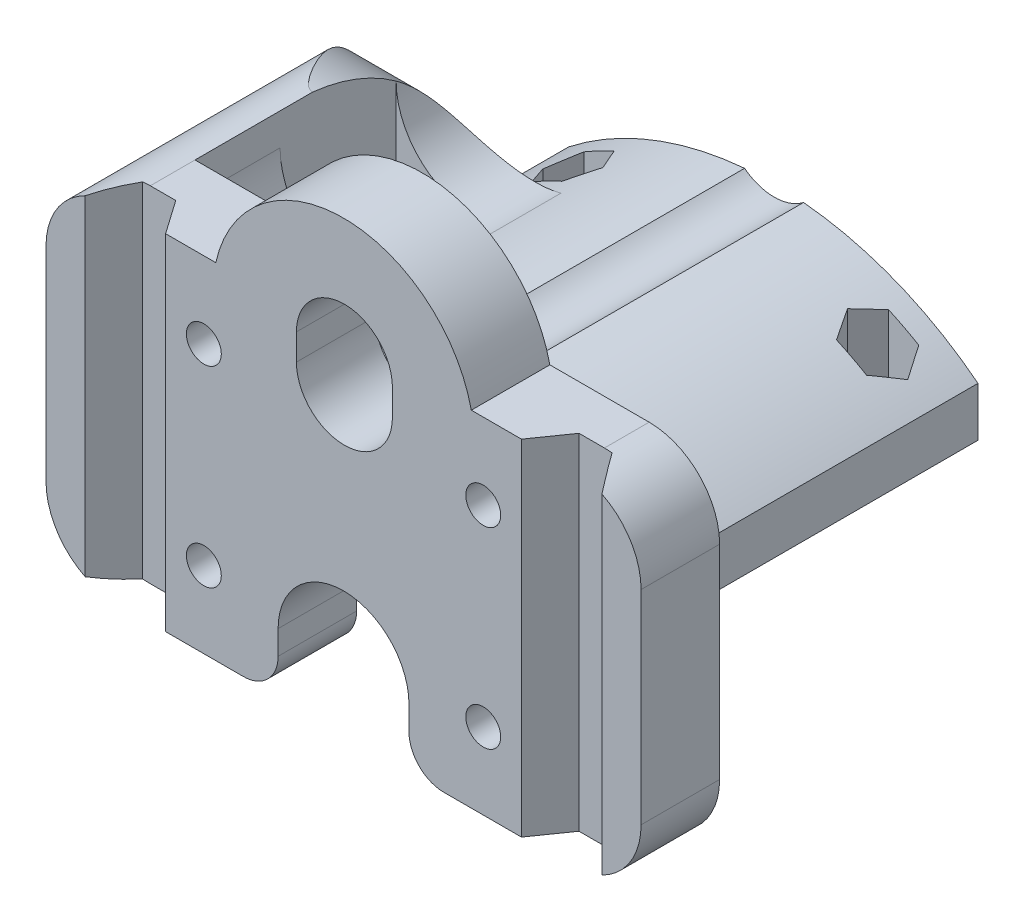
from build123d import *

# Parameters (mm, degrees)
SKETCH1_R           = 2
BOSS_EXTRUDE1_DEPTH = 49.25
SKETCH2_R           = 2
CUT_EXTRUDE1_DEPTH  = 40.25
CUT_EXTRUDE2_DEPTH  = 50.25
BOSS_EXTRUDE2_DEPTH = 30.5
CUT_EXTRUDE3_REACH  = 70.2
BOSS_EXTRUDE3_DEPTH = 19.5
CUT_EXTRUDE4_DEPTH  = 19.5
CUT_EXTRUDE5_DEPTH  = 40.5
SKETCH9_R           = 4.05
CUT_EXTRUDE6_DEPTH  = 2.4
CUT_EXTRUDE7_REACH  = 41.5
CUT_EXTRUDE8_REACH  = 70.2
SKETCH11_R          = 4.5
CUT_EXTRUDE9_REACH  = 36.95
SKETCH12_R          = 1.8
CUT_EXTRUDE10_REACH = 34.6


with BuildPart() as part:
    # Sketch1 → Boss-Extrude1 (new body)
    with BuildSketch(Plane.XY):
        with BuildLine():
            Line((14.643684646, 19.75), (26.025, 19.75))
            ThreePointArc((26.025, 19.75), (31.734887258, 17.384887258), (34.1, 11.675))
            Line((34.1, 11.675), (34.1, -11.675))
            ThreePointArc((34.1, -11.675), (31.734887258, -17.384887258), (26.025, -19.75))
            Line((26.025, -19.75), (11.5, -19.75))
            ThreePointArc((11.5, -19.75), (8.671572875, -18.578427125), (7.5, -15.75))
            Line((7.5, -15.75), (7.5, -13))
            ThreePointArc((7.5, -13), (0, -5.5), (-7.5, -13))
            Line((-7.5, -13), (-7.5, -15.75))
            ThreePointArc((-7.5, -15.75), (-8.671572875, -18.578427125), (-11.5, -19.75))
            Line((-11.5, -19.75), (-26.025, -19.75))
            ThreePointArc((-26.025, -19.75), (-31.734887258, -17.384887258), (-34.1, -11.675))
            Line((-34.1, -11.675), (-34.1, 11.675))
            ThreePointArc((-34.1, 11.675), (-31.734887258, 17.384887258), (-26.025, 19.75))
            Line((-26.025, 19.75), (-14.643684646, 19.75))
            ThreePointArc((-14.643684646, 19.75), (0, 31.5), (14.643684646, 19.75))
        make_face()
        with Locations((-16.01, -11)):
            Circle(SKETCH1_R, mode=Mode.SUBTRACT)
        with Locations((16.01, -11)):
            Circle(SKETCH1_R, mode=Mode.SUBTRACT)
        with Locations((-16.01, 11)):
            Circle(SKETCH1_R, mode=Mode.SUBTRACT)
        with Locations((16.01, 11)):
            Circle(SKETCH1_R, mode=Mode.SUBTRACT)
    extrude(amount=-BOSS_EXTRUDE1_DEPTH)

    # Sketch2 → Cut-Extrude1 (cut)
    with BuildSketch(Plane(origin=(0, 0, -49.25), x_dir=(-1, 0, 0), z_dir=(0, 0, -1))):
        with BuildLine():
            Line((11.5, -19.75), (26.025, -19.75))
            ThreePointArc((26.025, -19.75), (31.734887258, -17.384887258), (34.1, -11.675))
            Line((34.1, -11.675), (34.1, 11.675))
            ThreePointArc((34.1, 11.675), (31.734887258, 17.384887258), (26.025, 19.75))
            Line((26.025, 19.75), (14.643684646, 19.75))
            ThreePointArc((14.643684646, 19.75), (0, 31.5), (-14.643684646, 19.75))
            Line((-14.643684646, 19.75), (-26.025, 19.75))
            ThreePointArc((-26.025, 19.75), (-31.734887258, 17.384887258), (-34.1, 11.675))
            Line((-34.1, 11.675), (-34.1, -11.675))
            ThreePointArc((-34.1, -11.675), (-31.734887258, -17.384887258), (-26.025, -19.75))
            Line((-26.025, -19.75), (-11.5, -19.75))
            ThreePointArc((-11.5, -19.75), (-8.671572875, -18.578427125), (-7.5, -15.75))
            Line((-7.5, -15.75), (-7.5, -13))
            ThreePointArc((-7.5, -13), (0, -5.5), (7.5, -13))
            Line((7.5, -13), (7.5, -15.75))
            ThreePointArc((7.5, -15.75), (8.671572875, -18.578427125), (11.5, -19.75))
        make_face()
        with Locations((-16.01, -11)):
            Circle(SKETCH2_R, mode=Mode.SUBTRACT)
        with Locations((16.01, -11)):
            Circle(SKETCH2_R, mode=Mode.SUBTRACT)
        with BuildLine():
            Line((23.4625, -3.45), (-23.4625, -3.45))
            Line((-23.4625, -3.45), (-23.4625, 2.2))
            ThreePointArc((-23.4625, 2.2), (0, 10.309700625), (23.4625, 2.2))
            Line((23.4625, 2.2), (23.4625, -3.45))
        make_face(mode=Mode.SUBTRACT)
        with Locations((-16.01, 11)):
            Circle(SKETCH2_R, mode=Mode.SUBTRACT)
        with Locations((16.01, 11)):
            Circle(SKETCH2_R, mode=Mode.SUBTRACT)
    extrude(amount=-CUT_EXTRUDE1_DEPTH, mode=Mode.SUBTRACT)

    # Sketch3 → Cut-Extrude2 (cut, through all)
    with BuildSketch(Plane(origin=(0, 0, -49.25), x_dir=(-1, 0, 0), z_dir=(0, 0, -1))):
        with BuildLine():
            Line((5.400029356, 17.5), (5.400029356, 14.500008735))
            ThreePointArc((5.400029356, 14.500008735), (-0.099987836, 8.999989471), (-5.600009173, 14.500004591))
            Line((-5.600009173, 14.500004591), (-5.600029356, 17.499962997))
            ThreePointArc((-5.600029356, 17.499962997), (-0.100018502, 23.000029356), (5.400029356, 17.5))
        make_face()
    extrude(amount=-CUT_EXTRUDE2_DEPTH, mode=Mode.SUBTRACT)

    # Sketch4 → Boss-Extrude2 (add)
    with BuildSketch(Plane(origin=(0, 0, -9), x_dir=(-1, 0, 0), z_dir=(0, 0, -1))):
        with BuildLine():
            ThreePointArc((34.1, 11.675), (31.734887258, 17.384887258), (26.025, 19.75))
            Line((26.025, 19.75), (26.025, 16.08))
            ThreePointArc((26.025, 16.08), (22.115315274, 8.671322277), (13.792758824, 7.717805418))
            ThreePointArc((13.792758824, 7.717805418), (18.830829022, 5.315002189), (23.4625, 2.2))
            Line((23.4625, 2.2), (23.4625, -3.45))
            Line((23.4625, -3.45), (26.6625, -3.45))
            Line((26.6625, -3.45), (26.6625, -19.724796193))
            ThreePointArc((26.6625, -19.724796193), (31.955996438, -17.154863707), (34.1, -11.675))
            Line((34.1, -11.675), (34.1, 11.675))
        make_face()
    extrude(amount=BOSS_EXTRUDE2_DEPTH)

    # Sketch5 → Cut-Extrude3 (cut, up to next)
    with BuildSketch(Plane.ZY.offset(34.1), mode=Mode.PRIVATE) as cut_extrude3_sk1:
        with BuildLine():
            ThreePointArc((-36.446473341, 11.675), (-30.322556644, 17.17937534), (-22.5, 19.75))
            Line((-22.5, 19.75), (-39.5, 19.75))
            Line((-39.5, 19.75), (-39.5, 11.675))
            Line((-39.5, 11.675), (-36.446473341, 11.675))
        make_face()
    cut_extrude3_tool1 = extrude(cut_extrude3_sk1.sketch, amount=-CUT_EXTRUDE3_REACH, mode=Mode.PRIVATE) & part.part
    add(cut_extrude3_tool1.solids().sort_by_distance((-34.1, 16.750328, -34.812411))[0], mode=Mode.SUBTRACT)
    # Sketch5 → Cut-Extrude3 (cut, up to next)
    with BuildSketch(Plane.ZY.offset(34.1), mode=Mode.PRIVATE) as cut_extrude3_sk2:
        with BuildLine():
            ThreePointArc((-39.5, 5.475203807), (-38.243056783, 8.707993837), (-36.446473341, 11.675))
            Line((-36.446473341, 11.675), (-39.5, 11.675))
            Line((-39.5, 11.675), (-39.5, 5.475203807))
        make_face()
    cut_extrude3_tool2 = extrude(cut_extrude3_sk2.sketch, amount=-CUT_EXTRUDE3_REACH, mode=Mode.PRIVATE) & part.part
    add(cut_extrude3_tool2.solids().sort_by_distance((-34.1, 9.776794, -38.55104))[0], mode=Mode.SUBTRACT)

    # Sketch6 → Boss-Extrude3 (add)
    with BuildSketch(Plane(origin=(0, 0, -49.25), x_dir=(-1, 0, 0), z_dir=(0, 0, -1))):
        with BuildLine():
            Line((-23.4625, 2.2), (-23.4625, -3.45))
            Line((-23.4625, -3.45), (23.4625, -3.45))
            Line((23.4625, -3.45), (23.4625, 2.2))
            ThreePointArc((23.4625, 2.2), (13.955756335, 7.653869971), (3.287761431, 10.167186009))
            ThreePointArc((3.287761431, 10.167186009), (-0.086953501, 9.00000492), (-3.467163514, 10.151175119))
            ThreePointArc((-3.467163514, 10.151175119), (-14.039479716, 7.620692104), (-23.4625, 2.2))
        make_face()
    extrude(amount=-BOSS_EXTRUDE3_DEPTH)

    # Sketch7 → Cut-Extrude4 (cut)
    with BuildSketch(Plane.ZY.offset(34.1)):
        with BuildLine():
            Line((-39.5, -5.75), (-39.5, -19.724796193))
            Line((-39.5, -19.724796193), (-23.95, -19.724796193))
            ThreePointArc((-23.95, -19.724796193), (-33.696416785, -14.931028013), (-39.5, -5.75))
        make_face()
    extrude(amount=-CUT_EXTRUDE4_DEPTH, mode=Mode.SUBTRACT)

    # Sketch8 → Cut-Extrude5 (cut)
    with BuildSketch(Plane(origin=(0, 19.75, 0), x_dir=(1, 0, 0), z_dir=(0, 1, 0))):
        Polygon((-17.075, 32.05), (-26.025, 32.05), (-26.025, 18.75), (-18.960500232, 18.75), (-17.075, 20.635500232), align=None)
    extrude(amount=-CUT_EXTRUDE5_DEPTH, mode=Mode.SUBTRACT)

    # Sketch9 → Cut-Extrude6 (cut)
    with BuildSketch(Plane(origin=(0, 0, -9), x_dir=(-1, 0, 0), z_dir=(0, 0, -1))):
        with Locations((-16.01, 11)):
            Circle(SKETCH9_R)
        with Locations((16.01, 11)):
            Circle(SKETCH9_R)
        with Locations((-16.01, -11)):
            Circle(SKETCH9_R)
        with Locations((16.01, -11)):
            Circle(SKETCH9_R)
    extrude(amount=-CUT_EXTRUDE6_DEPTH, mode=Mode.SUBTRACT)

    # Sketch10 → Cut-Extrude7 (cut, up to next)
    with BuildSketch(Plane(origin=(0, 19.75, 0), x_dir=(1, 0, 0), z_dir=(0, 1, 0)), mode=Mode.PRIVATE) as cut_extrude7_sk1:
        Polygon((20.391684646, 0), (23.107093003, 3.878005034), (26.897093003, 3.878005034), (29.612501361, 0), align=None)
    cut_extrude7_tool1 = extrude(cut_extrude7_sk1.sketch, amount=-CUT_EXTRUDE7_REACH, mode=Mode.PRIVATE) & part.part
    add(cut_extrude7_tool1.solids().sort_by_distance((25.002093, 19.75, -1.669218))[0], mode=Mode.SUBTRACT)
    # Sketch10 → Cut-Extrude7 (cut, up to next)
    with BuildSketch(Plane(origin=(0, 19.75, 0), x_dir=(1, 0, 0), z_dir=(0, 1, 0)), mode=Mode.PRIVATE) as cut_extrude7_sk2:
        Polygon((-20.391584646, 0), (-23.106993003, 3.878005034), (-26.896993003, 3.878005034), (-29.612401361, 0), align=None)
    cut_extrude7_tool2 = extrude(cut_extrude7_sk2.sketch, amount=-CUT_EXTRUDE7_REACH, mode=Mode.PRIVATE) & part.part
    add(cut_extrude7_tool2.solids().sort_by_distance((-25.001993, 19.75, -1.669218))[0], mode=Mode.SUBTRACT)

    # Sketch11 → Cut-Extrude8 (cut, up to next)
    with BuildSketch(Plane.ZY.offset(34.1), mode=Mode.PRIVATE) as cut_extrude8_sk1:
        with Locations((-25, 3.9)):
            Circle(SKETCH11_R)
    cut_extrude8_tool1 = extrude(cut_extrude8_sk1.sketch, amount=-CUT_EXTRUDE8_REACH, mode=Mode.PRIVATE) & part.part
    add(cut_extrude8_tool1.solids().sort_by_distance((-34.1, 3.9, -25))[0], mode=Mode.SUBTRACT)

    # Sketch12 → Cut-Extrude9 (cut, up to next)
    with BuildSketch(Plane.XZ.offset(3.45), mode=Mode.PRIVATE) as cut_extrude9_sk1:
        with Locations((-17.4625, -15)):
            Circle(SKETCH12_R)
    cut_extrude9_tool1 = extrude(cut_extrude9_sk1.sketch, amount=-CUT_EXTRUDE9_REACH, mode=Mode.PRIVATE) & part.part
    add(cut_extrude9_tool1.solids().sort_by_distance((-17.4625, -3.45, -15))[0], mode=Mode.SUBTRACT)
    # Sketch12 → Cut-Extrude9 (cut, up to next)
    with BuildSketch(Plane.XZ.offset(3.45), mode=Mode.PRIVATE) as cut_extrude9_sk2:
        with Locations((-17.4625, -43.75)):
            Circle(SKETCH12_R)
    cut_extrude9_tool2 = extrude(cut_extrude9_sk2.sketch, amount=-CUT_EXTRUDE9_REACH, mode=Mode.PRIVATE) & part.part
    add(cut_extrude9_tool2.solids().sort_by_distance((-17.4625, -3.45, -43.75))[0], mode=Mode.SUBTRACT)
    # Sketch12 → Cut-Extrude9 (cut, up to next)
    with BuildSketch(Plane.XZ.offset(3.45), mode=Mode.PRIVATE) as cut_extrude9_sk3:
        with Locations((17.4625, -15)):
            Circle(SKETCH12_R)
    cut_extrude9_tool3 = extrude(cut_extrude9_sk3.sketch, amount=-CUT_EXTRUDE9_REACH, mode=Mode.PRIVATE) & part.part
    add(cut_extrude9_tool3.solids().sort_by_distance((17.4625, -3.45, -15))[0], mode=Mode.SUBTRACT)
    # Sketch12 → Cut-Extrude9 (cut, up to next)
    with BuildSketch(Plane.XZ.offset(3.45), mode=Mode.PRIVATE) as cut_extrude9_sk4:
        with Locations((17.4625, -43.75)):
            Circle(SKETCH12_R)
    cut_extrude9_tool4 = extrude(cut_extrude9_sk4.sketch, amount=-CUT_EXTRUDE9_REACH, mode=Mode.PRIVATE) & part.part
    add(cut_extrude9_tool4.solids().sort_by_distance((17.4625, -3.45, -43.75))[0], mode=Mode.SUBTRACT)

    # Sketch13 → Cut-Extrude10 (cut, up to next)
    with BuildSketch(Plane(origin=(0, -1.1004, 0), x_dir=(-1, 0, 0), z_dir=(0, -1, 0)), mode=Mode.PRIVATE) as cut_extrude10_sk1:
        Polygon((-15.737425, 46.737917547), (-19.187575, 46.737917547), (-20.91265, 43.75), (-19.187575, 40.762082453), (-15.737425, 40.762082453), (-14.01235, 43.75), align=None)
    cut_extrude10_tool1 = extrude(cut_extrude10_sk1.sketch, amount=-CUT_EXTRUDE10_REACH, mode=Mode.PRIVATE) & part.part
    add(cut_extrude10_tool1.solids().sort_by_distance((17.4625, -1.1004, -43.75))[0], mode=Mode.SUBTRACT)
    # Sketch13 → Cut-Extrude10 (cut, up to next)
    with BuildSketch(Plane(origin=(0, -1.1004, 0), x_dir=(-1, 0, 0), z_dir=(0, -1, 0)), mode=Mode.PRIVATE) as cut_extrude10_sk2:
        Polygon((-15.737425, 17.987917547), (-19.187575, 17.987917547), (-20.91265, 15), (-19.187575, 12.012082453), (-15.737425, 12.012082453), (-14.01235, 15), align=None)
    cut_extrude10_tool2 = extrude(cut_extrude10_sk2.sketch, amount=-CUT_EXTRUDE10_REACH, mode=Mode.PRIVATE) & part.part
    add(cut_extrude10_tool2.solids().sort_by_distance((17.4625, -1.1004, -15))[0], mode=Mode.SUBTRACT)
    # Sketch13 → Cut-Extrude10 (cut, up to next)
    with BuildSketch(Plane(origin=(0, -1.1004, 0), x_dir=(-1, 0, 0), z_dir=(0, -1, 0)), mode=Mode.PRIVATE) as cut_extrude10_sk3:
        Polygon((19.187575, 17.987917547), (15.737425, 17.987917547), (14.01235, 15), (15.737425, 12.012082453), (19.187575, 12.012082453), (20.91265, 15), align=None)
    cut_extrude10_tool3 = extrude(cut_extrude10_sk3.sketch, amount=-CUT_EXTRUDE10_REACH, mode=Mode.PRIVATE) & part.part
    add(cut_extrude10_tool3.solids().sort_by_distance((-17.4625, -1.1004, -15))[0], mode=Mode.SUBTRACT)
    # Sketch13 → Cut-Extrude10 (cut, up to next)
    with BuildSketch(Plane(origin=(0, -1.1004, 0), x_dir=(-1, 0, 0), z_dir=(0, -1, 0)), mode=Mode.PRIVATE) as cut_extrude10_sk4:
        Polygon((15.737425, 40.762082453), (19.187575, 40.762082453), (20.91265, 43.75), (19.187575, 46.737917547), (15.737425, 46.737917547), (14.01235, 43.75), align=None)
    cut_extrude10_tool4 = extrude(cut_extrude10_sk4.sketch, amount=-CUT_EXTRUDE10_REACH, mode=Mode.PRIVATE) & part.part
    add(cut_extrude10_tool4.solids().sort_by_distance((-17.4625, -1.1004, -43.75))[0], mode=Mode.SUBTRACT)


solid = part.part
